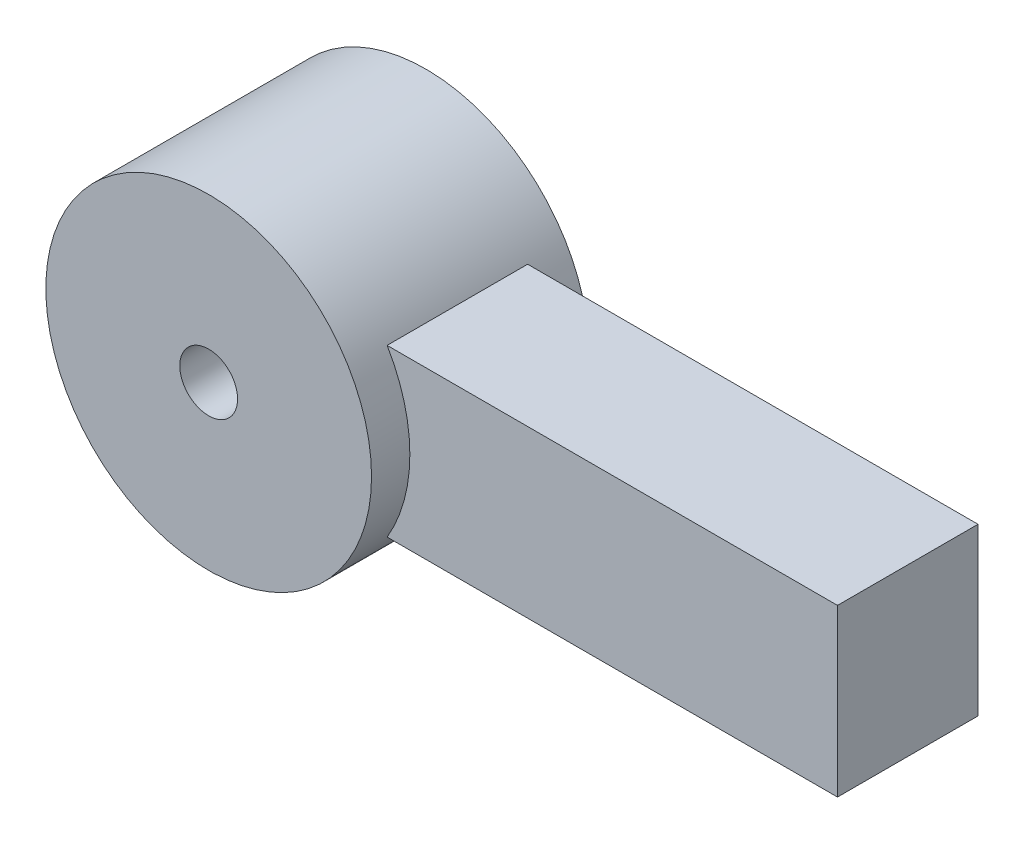
from build123d import *

# Parameters (mm, degrees)
BOSS_EXTRUDE1_DEPTH = 5.5
SKETCH1_3_R         = 2.261632510671041
BOSS_EXTRUDE2_DEPTH = 8.499999999999996


with BuildPart() as part:
    # Sketch1 → Boss-Extrude1 (new, symmetric)
    with BuildSketch(Plane.XY):
        with BuildLine():
            Line((10.96881949776985, -6.498209588575632), (46.22624128009294, -6.498209588575632))
            Line((46.22624128009294, -6.498209588575632), (46.22624128009294, 6.498209588575632))
            Line((46.22624128009294, 6.498209588575632), (10.96881949776985, 6.498209588575632))
            ThreePointArc((10.96881949776985, 6.498209588575631), (12.296040881424664, 3.3688436701701763), (12.74918542620321, 0))
            ThreePointArc((12.74918542620321, -3.12e-15), (12.296040881424664, -3.3688436701701785), (10.96881949776985, -6.498209588575633))
        make_face()
    extrude(amount=BOSS_EXTRUDE1_DEPTH, both=True)

    # Sketch1_3 → Boss-Extrude2 (add, symmetric)
    with BuildSketch(Plane.XY):
        with BuildLine():
            ThreePointArc((10.96881949776985, 6.498209588575631), (-12.74918542620321, 1.56e-15), (10.96881949776985, -6.498209588575633))
            ThreePointArc((10.96881949776985, -6.498209588575633), (12.296040881424664, -3.3688436701701785), (12.74918542620321, -3.12e-15))
            ThreePointArc((12.74918542620321, 0), (12.296040881424664, 3.3688436701701763), (10.96881949776985, 6.498209588575631))
        make_face()
        Circle(SKETCH1_3_R, mode=Mode.SUBTRACT)
    extrude(amount=BOSS_EXTRUDE2_DEPTH, both=True)


solid = part.part
